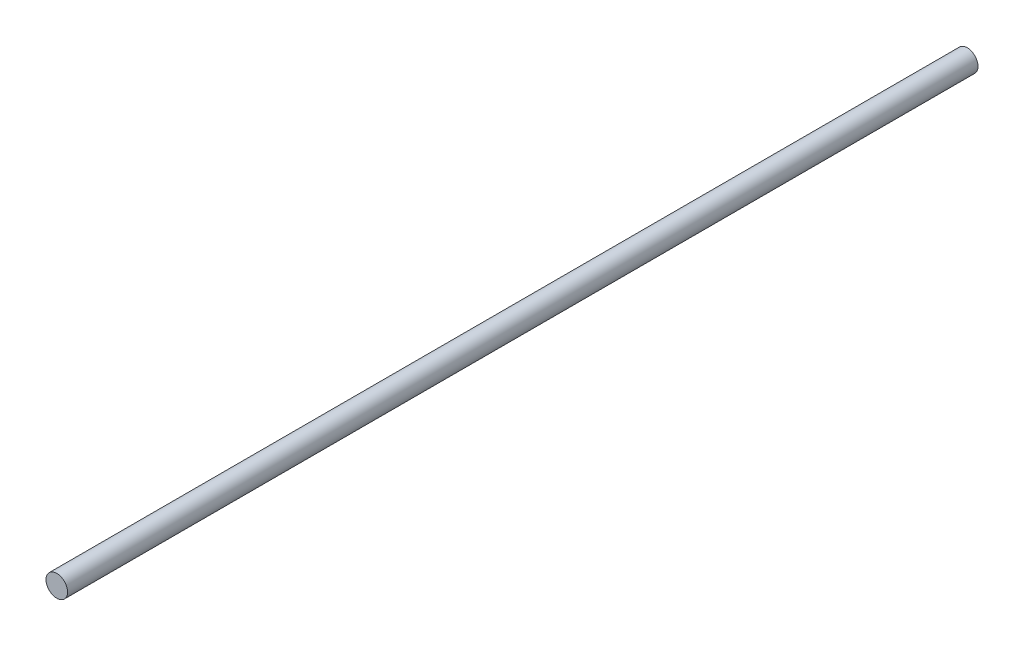
from build123d import *

# Parameters (mm, degrees)
SKETCH1_R           = 6.35
BOSS_EXTRUDE2_DEPTH = 268


with BuildPart() as part:
    # Sketch1 → Boss-Extrude2 (new body, symmetric)
    with BuildSketch(Plane.XY):
        Circle(SKETCH1_R)
    extrude(amount=BOSS_EXTRUDE2_DEPTH, both=True)


solid = part.part
